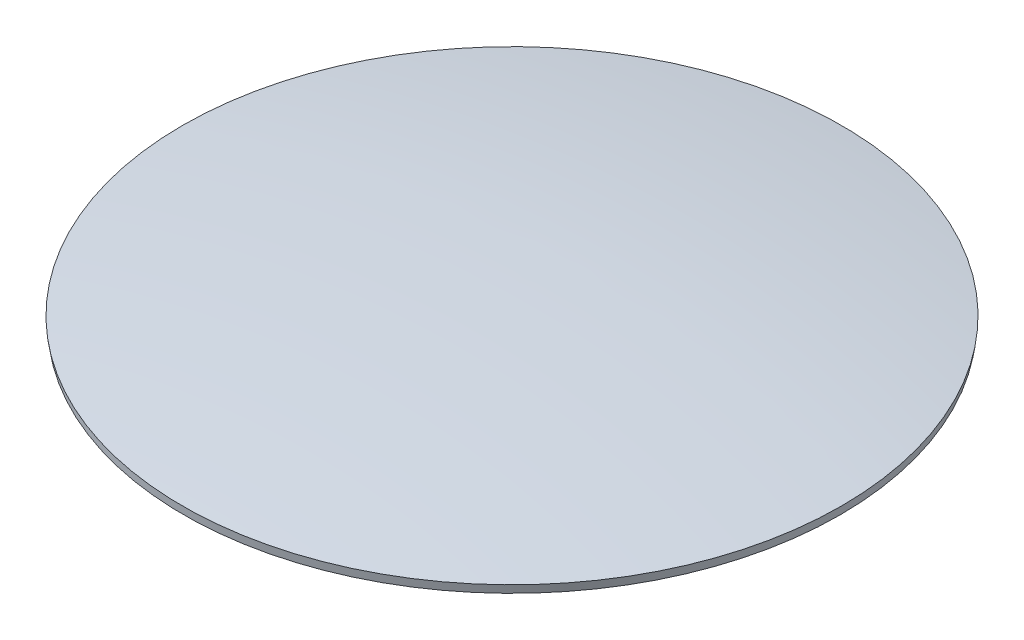
from build123d import *


with BuildPart() as part:
    # Esquisse1 → Révolution1 (revolve)
    with BuildSketch(Plane.XY):
        with BuildLine():
            Line((-19.5, 0.494071332), (-19.423230743, 0))
            ThreePointArc((-19.423230743, 0), (-9.740532487, 1.124442534), (0, 1.5))
            Line((0, 1.5), (0, 2))
            ThreePointArc((0, 2), (-9.779031408, 1.622958163), (-19.5, 0.494071332))
        make_face()
    revolve(axis=Axis((0, 2, 0), (0, -1, 0)))


solid = part.part
